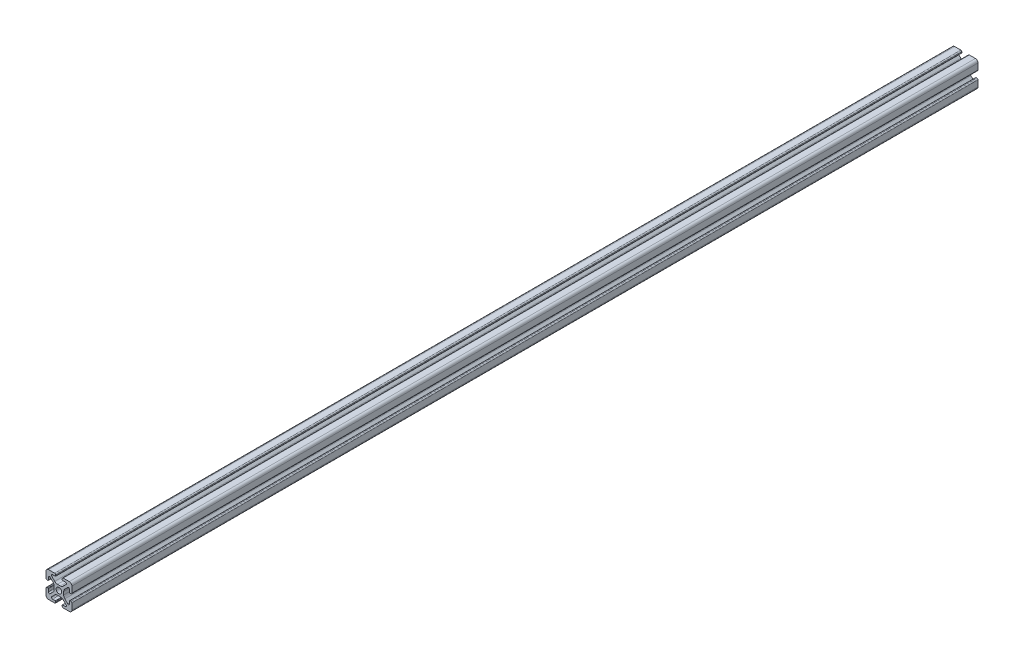
from build123d import *

# Parameters (mm, degrees)
SKETCH4_W              = 20
SKETCH4_H              = 20
BODY_DEPTH             = 700
SKETCH16_OUTSIDE_W     = 162.114
SKETCH16_OUTSIDE_H     = 162.114
SKETCH16_OUTSIDE_R     = 2.15
CUT_PROFILE_DEPTH      = 26
CUT_PROFILE_DEPTH_BACK = 676


with BuildPart() as part:
    # Sketch4 → Body (new body)
    with BuildSketch(Plane.XY.offset(25)):
        Rectangle(SKETCH4_W, SKETCH4_H)
    extrude(amount=-BODY_DEPTH)

    # Sketch16 outside → Cut-Profile (cut, two sides)
    with BuildSketch(Plane.XY) as cut_profile_sk:
        Rectangle(SKETCH16_OUTSIDE_W, SKETCH16_OUTSIDE_H)
        with BuildLine():
            Line((4.917588389, -8.199999991), (2.799999989, -8.199999991))
            ThreePointArc((2.799999989, -8.199999991), (2.587867955, -8.287867957), (2.499999989, -8.499999991))
            Line((2.499999989, -8.499999991), (2.499999989, -9.199999991))
            ThreePointArc((2.499999989, -9.199999991), (2.734314564, -9.765685416), (3.299999989, -9.999999991))
            Line((3.299999989, -9.999999991), (7.999999989, -9.999999991))
            ThreePointArc((7.999999989, -9.999999991), (9.414213552, -9.414213554), (9.999999989, -7.999999991))
            Line((9.999999989, -7.999999991), (9.999999989, -3.299999991))
            ThreePointArc((9.999999989, -3.299999991), (9.765685414, -2.734314566), (9.199999989, -2.499999991))
            Line((9.199999989, -2.499999991), (8.499999989, -2.499999991))
            ThreePointArc((8.499999989, -2.499999991), (8.287867955, -2.587867957), (8.199999989, -2.799999991))
            Line((8.199999989, -2.799999991), (8.199999989, -4.917588391))
            ThreePointArc((8.199999989, -4.917588391), (7.686138511, -5.686636441), (6.778984485, -5.506192286))
            Line((6.778984485, -5.506192286), (4.528679645, -3.255887446))
            ThreePointArc((4.528679645, -3.255887446), (3.878361392, -2.282617401), (3.64999999, -1.134567106))
            Line((3.64999999, -1.134567106), (3.64999999, 1.134567104))
            ThreePointArc((3.64999999, 1.134567104), (3.878361393, 2.282617402), (4.528679647, 3.255887448))
            Line((4.528679647, 3.255887448), (6.778984487, 5.506192288))
            ThreePointArc((6.778984487, 5.506192288), (7.686138506, 5.686636442), (8.199999981, 4.917588398))
            Line((8.199999981, 4.917588398), (8.199999981, 2.799999998))
            ThreePointArc((8.199999981, 2.799999998), (8.287867946, 2.587867964), (8.499999981, 2.499999998))
            Line((8.499999981, 2.499999998), (9.199999981, 2.499999998))
            ThreePointArc((9.199999981, 2.499999998), (9.765685406, 2.734314573), (9.999999981, 3.299999998))
            Line((9.999999981, 3.299999998), (9.999999981, 7.999999998))
            ThreePointArc((9.999999981, 7.999999998), (9.414213543, 9.41421356), (7.999999981, 9.999999998))
            Line((7.999999981, 9.999999998), (3.299999981, 9.999999998))
            ThreePointArc((3.299999981, 9.999999998), (2.734314556, 9.765685423), (2.499999981, 9.199999998))
            Line((2.499999981, 9.199999998), (2.499999981, 8.499999998))
            ThreePointArc((2.499999981, 8.499999998), (2.587867946, 8.287867964), (2.799999981, 8.199999998))
            Line((2.799999981, 8.199999998), (4.917588381, 8.199999998))
            ThreePointArc((4.917588381, 8.199999998), (5.68663643, 7.68613852), (5.506192275, 6.778984494))
            Line((5.506192275, 6.778984494), (3.255887435, 4.528679654))
            ThreePointArc((3.255887435, 4.528679654), (2.28261739, 3.878361401), (1.134567095, 3.649999999))
            Line((1.134567095, 3.649999999), (-1.134567115, 3.649999999))
            ThreePointArc((-1.134567115, 3.649999999), (-2.282617412, 3.878361401), (-3.255887459, 4.528679655))
            Line((-3.255887459, 4.528679655), (-5.506192299, 6.778984495))
            ThreePointArc((-5.506192299, 6.778984495), (-5.686636452, 7.686138515), (-4.917588409, 8.199999989))
            Line((-4.917588409, 8.199999989), (-2.800000009, 8.199999989))
            ThreePointArc((-2.800000009, 8.199999989), (-2.587867974, 8.287867955), (-2.500000009, 8.499999989))
            Line((-2.500000009, 8.499999989), (-2.500000009, 9.199999989))
            ThreePointArc((-2.500000009, 9.199999989), (-2.734314584, 9.765685414), (-3.300000009, 9.999999989))
            Line((-3.300000009, 9.999999989), (-8.000000009, 9.999999989))
            ThreePointArc((-8.000000009, 9.999999989), (-9.414213571, 9.414213552), (-10.000000009, 7.999999989))
            Line((-10.000000009, 7.999999989), (-10.000000009, 3.299999989))
            ThreePointArc((-10.000000009, 3.299999989), (-9.765685434, 2.734314564), (-9.200000009, 2.499999989))
            Line((-9.200000009, 2.499999989), (-8.500000009, 2.499999989))
            ThreePointArc((-8.500000009, 2.499999989), (-8.287867974, 2.587867955), (-8.200000009, 2.799999989))
            Line((-8.200000009, 2.799999989), (-8.200000009, 4.917588389))
            ThreePointArc((-8.200000009, 4.917588389), (-7.686138531, 5.686636438), (-6.778984504, 5.506192284))
            Line((-6.778984504, 5.506192284), (-4.528679664, 3.255887444))
            ThreePointArc((-4.528679664, 3.255887444), (-3.878361412, 2.282617399), (-3.650000009, 1.134567104))
            Line((-3.650000009, 1.134567104), (-3.650000009, -1.134567106))
            ThreePointArc((-3.650000009, -1.134567106), (-3.878361412, -2.282617404), (-4.528679666, -3.25588745))
            Line((-4.528679666, -3.25588745), (-6.778984506, -5.50619229))
            ThreePointArc((-6.778984506, -5.50619229), (-7.686138526, -5.686636444), (-8.2, -4.9175884))
            Line((-8.2, -4.9175884), (-8.2, -2.8))
            ThreePointArc((-8.2, -2.8), (-8.287867966, -2.587867966), (-8.5, -2.5))
            Line((-8.5, -2.5), (-9.2, -2.5))
            ThreePointArc((-9.2, -2.5), (-9.765685425, -2.734314575), (-10, -3.3))
            Line((-10, -3.3), (-10, -8))
            ThreePointArc((-10, -8), (-9.414213562, -9.414213562), (-8, -10))
            Line((-8, -10), (-3.3, -10))
            ThreePointArc((-3.3, -10), (-2.734314575, -9.765685425), (-2.5, -9.2))
            Line((-2.5, -9.2), (-2.5, -8.5))
            ThreePointArc((-2.5, -8.5), (-2.587867966, -8.287867966), (-2.8, -8.2))
            Line((-2.8, -8.2), (-4.9175884, -8.2))
            ThreePointArc((-4.9175884, -8.2), (-5.686636449, -7.686138522), (-5.506192294, -6.778984496))
            Line((-5.506192294, -6.778984496), (-3.255887454, -4.528679656))
            ThreePointArc((-3.255887454, -4.528679656), (-2.282617409, -3.878361403), (-1.134567114, -3.650000001))
            Line((-1.134567114, -3.650000001), (1.134567096, -3.650000001))
            ThreePointArc((1.134567096, -3.650000001), (2.282617393, -3.878361403), (3.255887439, -4.528679657))
            Line((3.255887439, -4.528679657), (5.506192279, -6.778984497))
            ThreePointArc((5.506192279, -6.778984497), (5.686636433, -7.686138517), (4.917588389, -8.199999991))
        make_face(mode=Mode.SUBTRACT)
        Circle(SKETCH16_OUTSIDE_R)
    extrude(amount=CUT_PROFILE_DEPTH, mode=Mode.SUBTRACT)
    extrude(cut_profile_sk.sketch, amount=-CUT_PROFILE_DEPTH_BACK, mode=Mode.SUBTRACT)


solid = part.part
